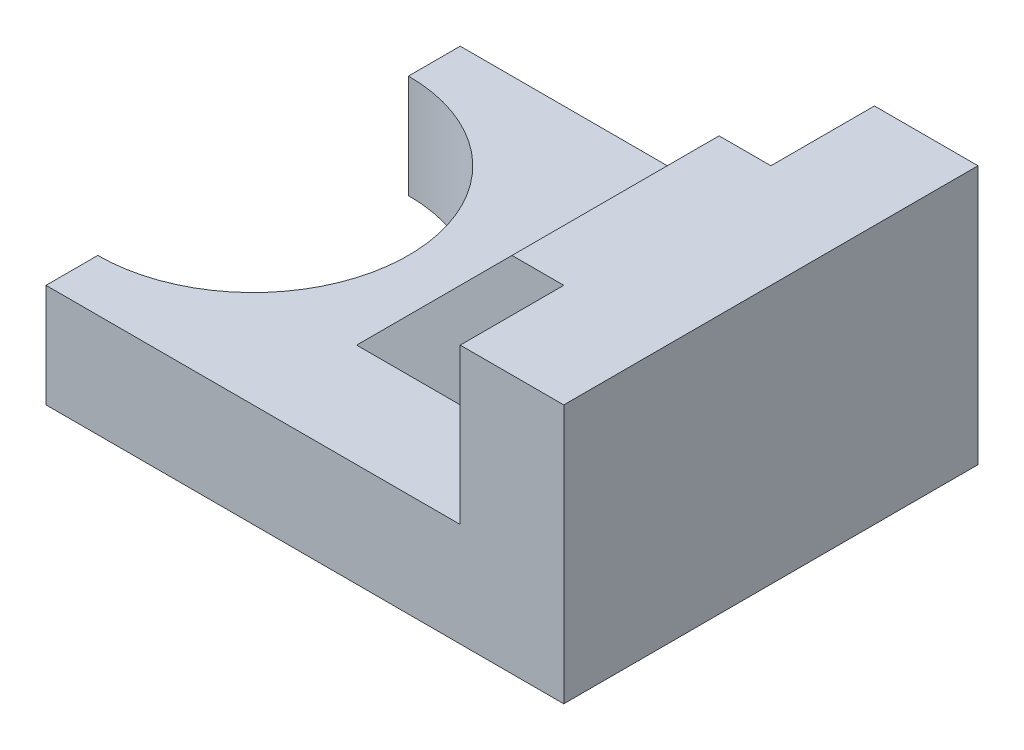
from build123d import *

# Parameters (mm, degrees)
BOSS_EXTRUDE1_DEPTH     = 20
CUT_EXTRUDE1_DEPTH      = 1
CUT_EXTRUDE1_DEPTH_BACK = 10
CUT_EXTRUDE2_DEPTH      = 10
CUT_EXTRUDE3_REACH      = 12


with BuildPart() as part:
    # Sketch1 → Boss-Extrude1 (new body, symmetric)
    with BuildSketch(Plane.XY):
        Polygon((-4.511794911, -6.86440678), (15.488205089, -6.86440678), (15.488205089, 8.13559322), (25.488205089, 8.13559322), (25.488205089, -16.86440678), (-24.511794911, -16.86440678), (-24.511794911, -6.86440678), align=None)
        Polygon((10.488205089, 8.13559322), (-4.511794911, -6.86440678), (15.488205089, -6.86440678), (15.488205089, 8.13559322), align=None)
    extrude(amount=BOSS_EXTRUDE1_DEPTH, both=True)

    # Sketch2 → Cut-Extrude1 (cut, two sides)
    with BuildSketch(Plane.XY.offset(20)) as cut_extrude1_sk:
        Polygon((-4.511794911, -6.86440678), (15.488205089, -6.86440678), (15.488205089, 8.13559322), (10.488205089, 8.13559322), align=None)
    extrude(amount=CUT_EXTRUDE1_DEPTH, mode=Mode.SUBTRACT)
    extrude(cut_extrude1_sk.sketch, amount=-CUT_EXTRUDE1_DEPTH_BACK, mode=Mode.SUBTRACT)

    # Sketch3 → Cut-Extrude2 (cut)
    with BuildSketch(Plane(origin=(0, 0, -20), x_dir=(-1, 0, 0), z_dir=(0, 0, -1))):
        Polygon((4.511794911, -6.86440678), (-15.488205089, -6.86440678), (-15.488205089, 8.13559322), (-10.488205089, 8.13559322), align=None)
    extrude(amount=-CUT_EXTRUDE2_DEPTH, mode=Mode.SUBTRACT)

    # Sketch4 → Cut-Extrude3 (cut, up to next)
    with BuildSketch(Plane(origin=(0, -6.86440678, 0), x_dir=(1, 0, 0), z_dir=(0, 1, 0)), mode=Mode.PRIVATE) as cut_extrude3_sk1:
        with BuildLine():
            Line((-24.511794911, 15), (-24.511794911, -15))
            ThreePointArc((-24.511794911, -15), (-9.511794911, 0), (-24.511794911, 15))
        make_face()
    cut_extrude3_tool1 = extrude(cut_extrude3_sk1.sketch, amount=-CUT_EXTRUDE3_REACH, mode=Mode.PRIVATE) & part.part
    add(cut_extrude3_tool1.solids().sort_by_distance((-18.145597, -6.864407, 0))[0], mode=Mode.SUBTRACT)


solid = part.part
